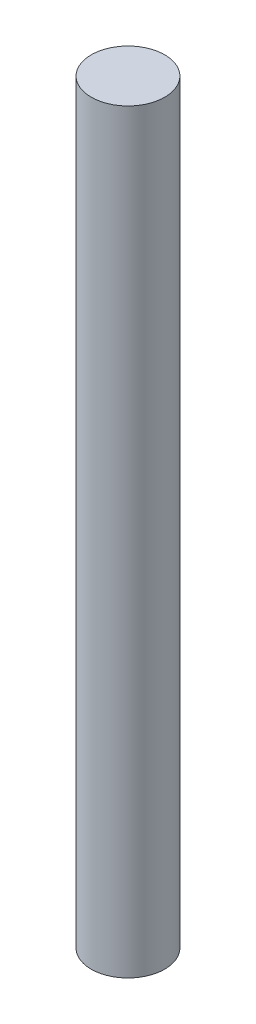
from build123d import *

# Parameters (mm, degrees)
SKETCH1_R           = 914.4
BOSS_EXTRUDE1_DEPTH = 18796


with BuildPart() as part:
    # Sketch1 → Boss-Extrude1 (new body)
    with BuildSketch(Plane(origin=(0, 0, 0), x_dir=(1, 0, 0), z_dir=(0, 1, 0))):
        Circle(SKETCH1_R)
    extrude(amount=BOSS_EXTRUDE1_DEPTH)


solid = part.part
